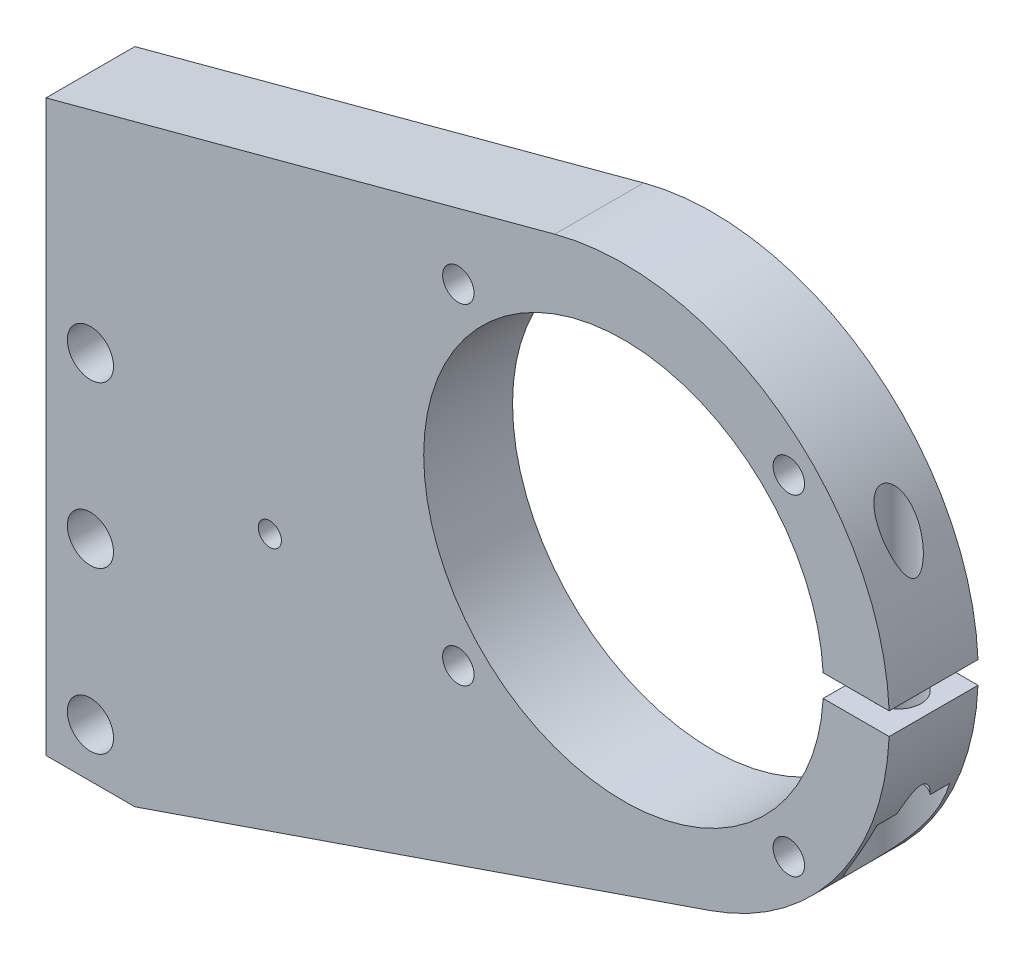
from build123d import *

# Parameters (mm, degrees)
BOSS_EXTRUDE1_DEPTH         = 12.7
CUT_EXTRUDE1_DEPTH          = 13.7
SKETCH3_W                   = 28.575
SKETCH3_H                   = 12.7
F_8_CLEARANCE_HOLE1_D       = 4.5
F_8_CLEARANCE_HOLE1_DEPTH   = 12.7
F_1_4_CLEARANCE_HOLE1_D     = 6.6
F_1_4_CLEARANCE_HOLE1_DEPTH = 12.7
F_12_CLEARANCE_HOLE1_D      = 6
F_12_CLEARANCE_HOLE1_DEPTH  = 12.7
HOLE1_D                     = 6.4
HOLE1_DEPTH                 = 24.77643101
HOLE1_CBORE_D               = 11.2
HOLE1_CBORE_DEPTH           = 11.77643101
F_10_CLEARANCE_HOLE1_D      = 5
F_10_CLEARANCE_HOLE1_DEPTH  = 36.4125
CHAMFER1_SIZE               = 3
SKETCH14_R                  = 3
SKETCH14_R_2                = 1.651
BOSS_EXTRUDE2_DEPTH         = 12.7


with BuildPart() as part:
    # Sketch1 → Boss-Extrude1 (new body)
    with BuildSketch(Plane(origin=(0, 0, 0), x_dir=(-1, 0, 0), z_dir=(0, 0, -1))):
        with BuildLine():
            Line((224.169455465, 127.72254562), (151.435240745, 147.211619716))
            ThreePointArc((151.435240745, 147.211619716), (105.257753851, 121.607458019), (129.246532787, 74.570537656))
            Line((129.246532787, 74.570537656), (211.469455465, 46.304993078))
            Line((211.469455465, 46.304993078), (224.169455465, 46.304993078))
            Line((224.169455465, 46.304993078), (224.169455465, 127.72254562))
        make_face()
    extrude(amount=-BOSS_EXTRUDE1_DEPTH)

    # Sketch2 → Cut-Extrude1 (cut, through all)
    with BuildSketch(Plane.XY.offset(12.7)):
        with BuildLine():
            Line((-103.633291463, 112.093938317), (-113.179018515, 112.093938317))
            ThreePointArc((-113.179018515, 112.093938317), (-113.134717032, 110.506438317), (-113.179018515, 108.918938317))
            Line((-113.179018515, 108.918938317), (-103.633291463, 108.918938317))
            ThreePointArc((-103.633291463, 108.918938317), (-103.600117032, 110.506438317), (-103.633291463, 112.093938317))
        make_face()
    extrude(amount=-CUT_EXTRUDE1_DEPTH, mode=Mode.SUBTRACT)

    # Sketch3 → Cut-Revolve1 (revolve, cut)
    with BuildSketch(Plane(origin=(0, 110.506438317, 0), x_dir=(1, 0, 0), z_dir=(0, 1, 0))):
        with Locations((-127.312617032, -6.35)):
            Rectangle(SKETCH3_W, SKETCH3_H)
    revolve(axis=Axis((-141.600117032, 110.506438317, 0), (0, 0, 1)), mode=Mode.SUBTRACT)

    # #8 Clearance Hole1
    with Locations(Plane.XY.offset(12.7)):
        with Locations((-117.978117032, 86.884438317), (-165.222117032, 86.884438317), (-165.222117032, 134.128438317), (-117.978117032, 134.128438317)):
            Hole(F_8_CLEARANCE_HOLE1_D / 2, depth=F_8_CLEARANCE_HOLE1_DEPTH)

    # 1/4 Clearance Hole1
    with Locations(Plane(origin=(0, 0, 0), x_dir=(-1, 0, 0), z_dir=(0, 0, -1))):
        with Locations((217.819455465, 53.304993078), (217.819455465, 76.304993078), (217.819455465, 99.304993078)):
            Hole(F_1_4_CLEARANCE_HOLE1_D / 2, depth=F_1_4_CLEARANCE_HOLE1_DEPTH)

    # #12 Clearance Hole1
    with Locations(Plane.XY.offset(12.7)):
        with Locations((-192.169455465, 89.72254562)):
            Hole(F_12_CLEARANCE_HOLE1_D / 2, depth=F_12_CLEARANCE_HOLE1_DEPTH)

    # Hole1
    with Locations(Plane(origin=(0, 84.142507307, 0), x_dir=(-1, 0, 0), z_dir=(0, -1, 0))):
        with Locations((108.633291463, -6.35)):
            CounterBoreHole(HOLE1_D / 2, HOLE1_CBORE_D / 2, HOLE1_CBORE_DEPTH, depth=HOLE1_DEPTH)

    # #10 Clearance Hole1
    with Locations(Plane(origin=(0, 112.093938317, 0), x_dir=(-1, 0, 0), z_dir=(0, -1, 0))):
        with Locations((108.633291463, -6.35)):
            Hole(F_10_CLEARANCE_HOLE1_D / 2, depth=F_10_CLEARANCE_HOLE1_DEPTH)

    # Chamfer1
    chamfer1_edges = [part.edges().sort_by_distance(p)[0] for p in [
        (-221.119455465, 99.304993078, 0),
        (-221.119455465, 76.304993078, 0),
        (-221.119455465, 53.304993078, 0),
    ]]
    chamfer(chamfer1_edges, length=CHAMFER1_SIZE)

    # Sketch14 → Boss-Extrude2 (add)
    with BuildSketch(Plane(origin=(0, 0, 0), x_dir=(-1, 0, 0), z_dir=(0, 0, -1))):
        with Locations((192.169455465, 89.72254562)):
            Circle(SKETCH14_R)
        with Locations((192.169455465, 89.72254562)):
            Circle(SKETCH14_R_2, mode=Mode.SUBTRACT)
    extrude(amount=-BOSS_EXTRUDE2_DEPTH)


solid = part.part
